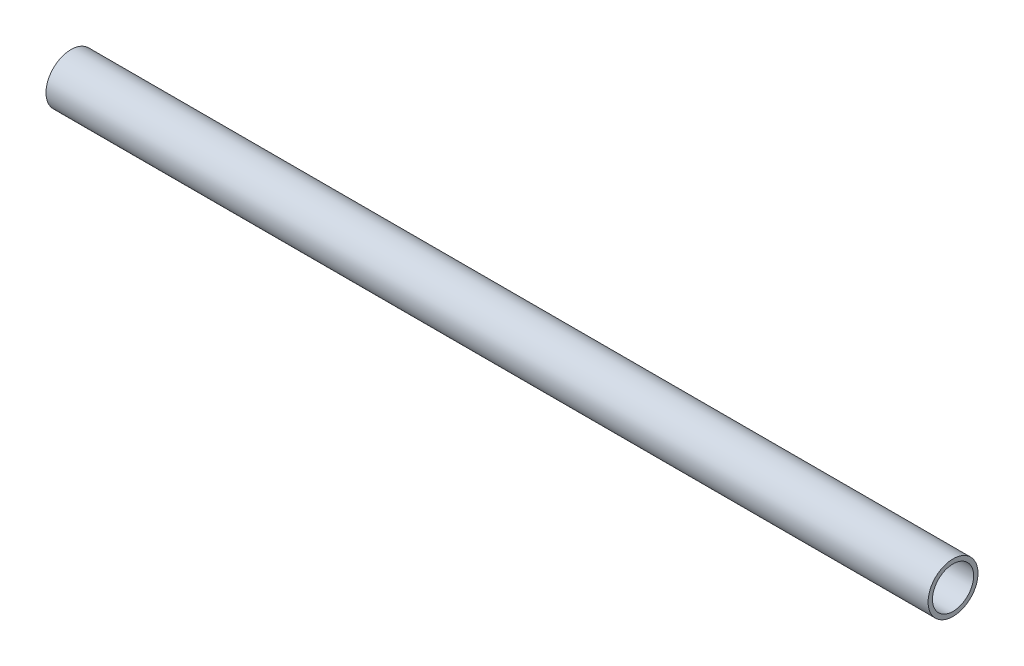
from build123d import *

# Parameters (mm, degrees)
SKETCH1_R               = 3.175
SKETCH1_R_2             = 2.6162
PIPE_0_5_SCH_40_1_DEPTH = 112.201630443


with BuildPart() as part:
    # Sketch1 → Pipe 0.5 SCH 40(1) (new body)
    with BuildSketch(Plane(origin=(-82.756071761, 647.702421083, 0), x_dir=(0, -1, 0), z_dir=(-1, 0, 0))):
        Circle(SKETCH1_R)
        Circle(SKETCH1_R_2, mode=Mode.SUBTRACT)
    extrude(amount=PIPE_0_5_SCH_40_1_DEPTH)


solid = part.part
